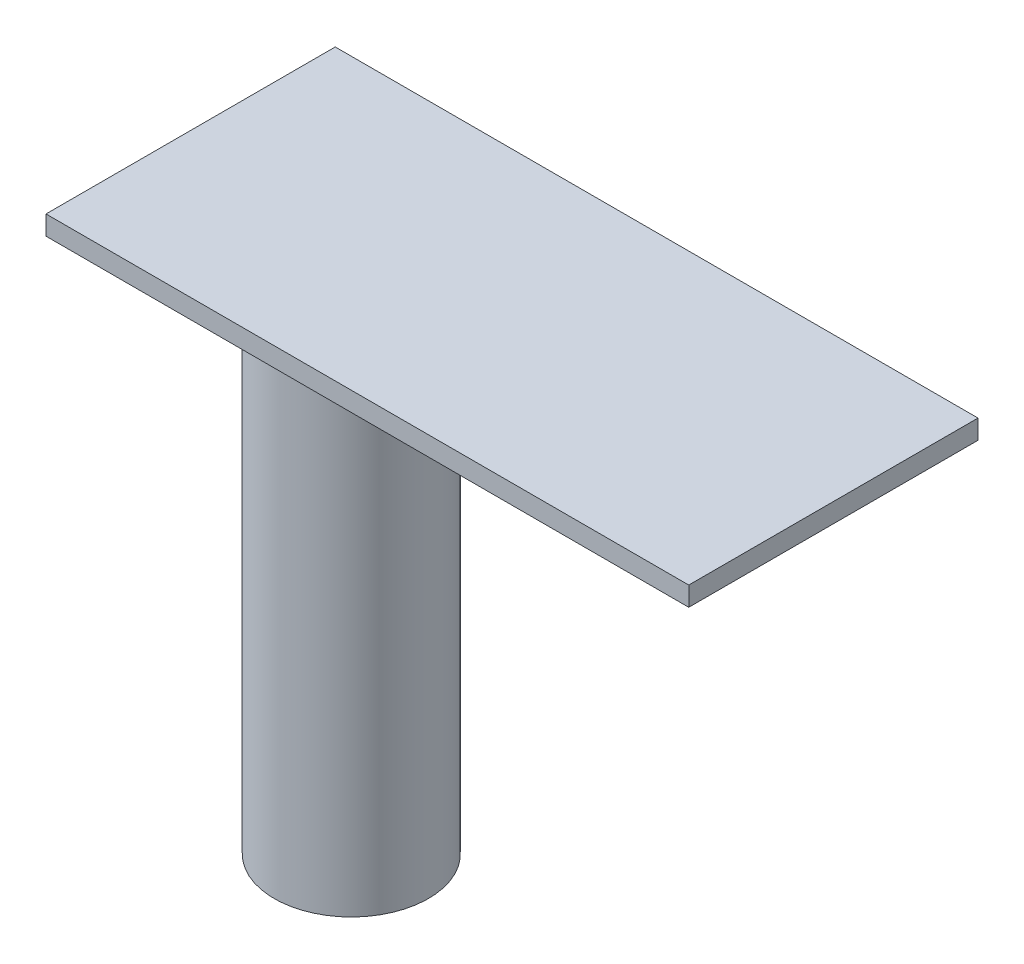
from build123d import *

# Parameters (mm, degrees)
SKETCH_1_W      = 100
SKETCH_1_H      = 45
EXTRUDE_1_DEPTH = 3
SKETCH_2_R      = 12
EXTRUDE_2_DEPTH = 82


with BuildPart() as part:
    # Эскиз1 → Бобышка-Вытянуть1 (new body)
    with BuildSketch(Plane(origin=(0, 0, 0), x_dir=(1, 0, 0), z_dir=(0, 1, 0))):
        with Locations((50, 22.5)):
            Rectangle(SKETCH_1_W, SKETCH_1_H)
    extrude(amount=EXTRUDE_1_DEPTH)

    # Эскиз2 → Бобышка-Вытянуть2 (add)
    with BuildSketch(Plane.XZ):
        with Locations((25, -22.5)):
            Circle(SKETCH_2_R)
    extrude(amount=EXTRUDE_2_DEPTH)


solid = part.part
